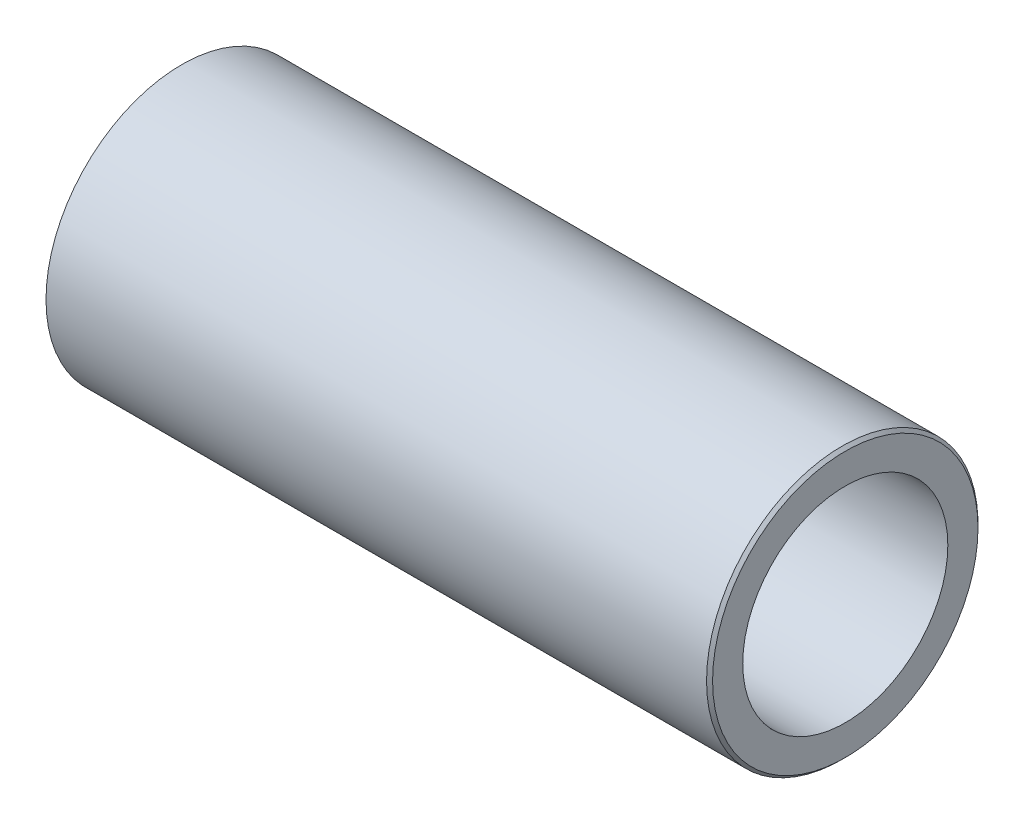
from build123d import *


with BuildPart() as part:
    # Sketch1 → Revolve1 (revolve)
    with BuildSketch(Plane.XY):
        Polygon((-55, 9), (-51, 9), (-51, 12), (9, 12), (9, 17), (55, 17), (55, 22), (54.5, 22.5), (-55, 22.5), align=None)
    revolve(axis=Axis((-55, 0, 0), (1, 0, 0)))


solid = part.part
